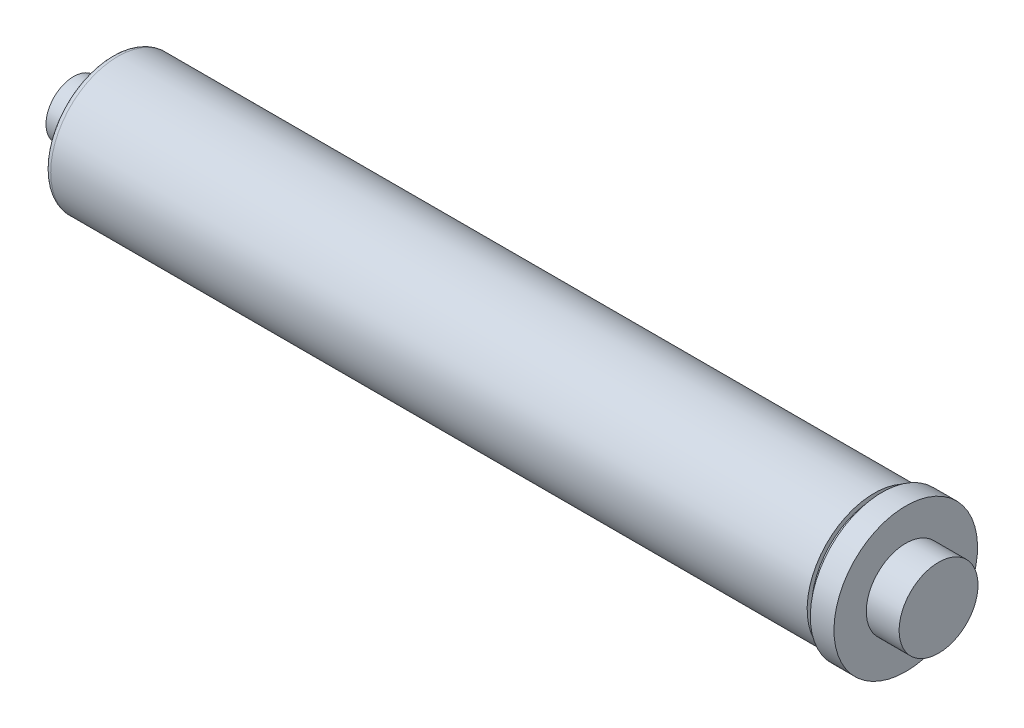
from build123d import *

# Parameters (mm, degrees)
FILLET1_R          = 2.54
SKETCH2_R          = 7.9375
CUT_EXTRUDE1_DEPTH = 6.35
SKETCH3_R          = 1.5875
CUT_EXTRUDE2_DEPTH = 6.35


with BuildPart() as part:
    # Sketch1 → Revolve1 (revolve)
    with BuildSketch(Plane.XY):
        Polygon((0, 0), (0, 11.1125), (15.24, 11.1125), (15.24, 26.9875), (322.199, 26.9875), (322.199, 25.1714), (325.374, 25.1714), (325.374, 28.8925), (334.899, 28.8925), (334.899, 15.875), (348.107, 15.875), (348.107, 0), align=None)
    revolve(axis=Axis((0, 0, 0), (1, 0, 0)))

    # Fillet1
    fillet1_edges = [part.edges().sort_by_distance(p)[0] for p in [
        (15.24, -26.9875, 0),
    ]]
    fillet(fillet1_edges, radius=FILLET1_R)

    # Sketch2 → Cut-Extrude1 (cut)
    with BuildSketch(Plane.ZY):
        Circle(SKETCH2_R)
    extrude(amount=-CUT_EXTRUDE1_DEPTH, mode=Mode.SUBTRACT)

    # Sketch3 → Cut-Extrude2 (cut)
    with BuildSketch(Plane.ZY.offset(-6.35)):
        Circle(SKETCH3_R)
    extrude(amount=-CUT_EXTRUDE2_DEPTH, mode=Mode.SUBTRACT)


solid = part.part
